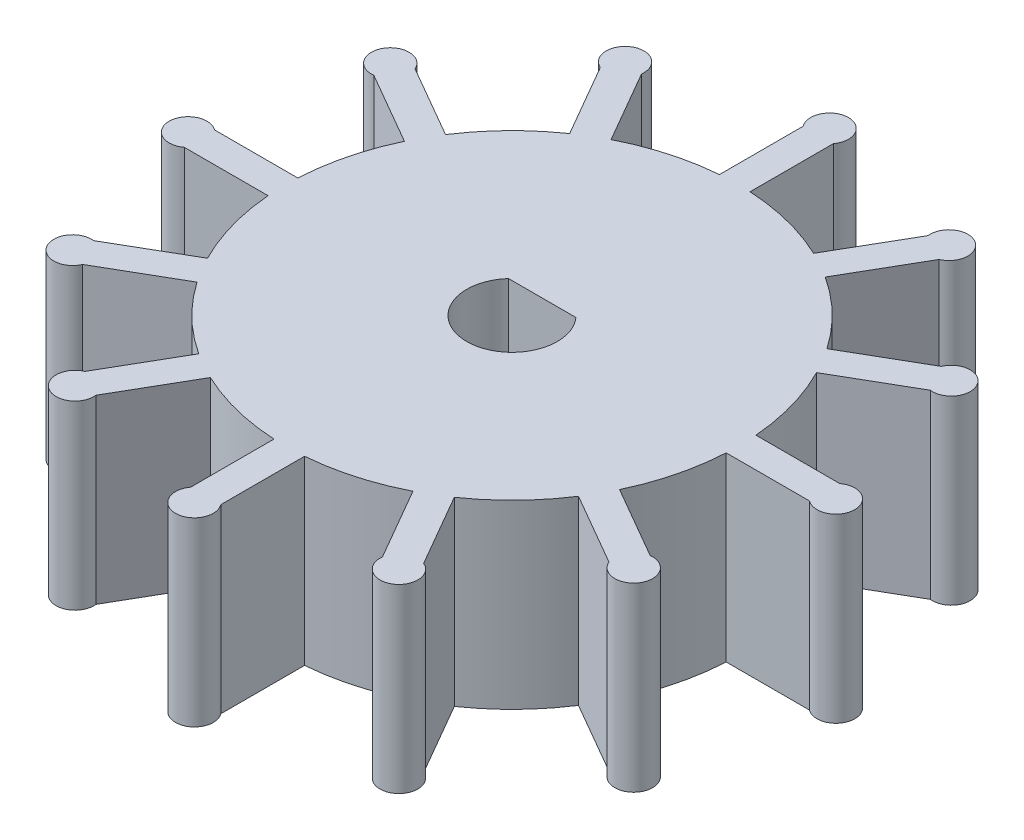
from build123d import *

# Parameters (mm, degrees)
BOSS_EXTRUDE1_DEPTH = 12
CUT_EXTRUDE1_DEPTH  = 13


with BuildPart() as part:
    # Sketch1 → Boss-Extrude1 (new body)
    with BuildSketch(Plane(origin=(0, 0, 0), x_dir=(1, 0, 0), z_dir=(0, 1, 0))):
        with BuildLine():
            Line((-1.209935044, 20.498962969), (-1.209935044, 14.951122272))
            ThreePointArc((-1.209935044, 14.951122272), (-4.085137635, 14.433005595), (-6.805373075, 13.367381842))
            Line((-6.805373075, 13.367381842), (-9.565265163, 18.147655161))
            ThreePointArc((-9.565265163, 18.147655161), (-11.431290566, 19.379705968), (-11.29731597, 17.147655161))
            Line((-11.29731597, 17.147655161), (-8.523395621, 12.34308418))
            ThreePointArc((-8.523395621, 12.34308418), (-10.754335768, 10.45678068), (-12.577316886, 8.17380572))
            Line((-12.577316886, 8.17380572), (-17.357590205, 10.933697807))
            ThreePointArc((-17.357590205, 10.933697807), (-19.589641013, 11.067672403), (-18.357590205, 9.201646999))
            Line((-18.357590205, 9.201646999), (-13.553019225, 6.427726651))
            ThreePointArc((-13.553019225, 6.427726651), (-14.541918316, 3.678669827), (-14.979178795, 0.790064956))
            Line((-14.979178795, 0.790064956), (-20.498962969, 0.790064956))
            ThreePointArc((-20.498962969, 0.790064956), (-22.498962969, -0.209935044), (-20.498962969, -1.209935044))
            Line((-20.498962969, -1.209935044), (-14.951122272, -1.209935044))
            ThreePointArc((-14.951122272, -1.209935044), (-14.433005595, -4.085137635), (-13.367381842, -6.805373075))
            Line((-13.367381842, -6.805373075), (-18.147655161, -9.565265163))
            ThreePointArc((-18.147655161, -9.565265163), (-19.379705968, -11.431290566), (-17.147655161, -11.29731597))
            Line((-17.147655161, -11.29731597), (-12.34308418, -8.523395621))
            ThreePointArc((-12.34308418, -8.523395621), (-10.45678068, -10.754335768), (-8.17380572, -12.577316886))
            Line((-8.17380572, -12.577316886), (-10.933697807, -17.357590205))
            ThreePointArc((-10.933697807, -17.357590205), (-11.067672403, -19.589641013), (-9.201646999, -18.357590205))
            Line((-9.201646999, -18.357590205), (-6.427726651, -13.553019225))
            ThreePointArc((-6.427726651, -13.553019225), (-3.678669827, -14.541918316), (-0.790064956, -14.979178795))
            Line((-0.790064956, -14.979178795), (-0.790064956, -20.498962969))
            ThreePointArc((-0.790064956, -20.498962969), (0.209935044, -22.498962969), (1.209935044, -20.498962969))
            Line((1.209935044, -20.498962969), (1.209935044, -14.951122272))
            ThreePointArc((1.209935044, -14.951122272), (4.085137635, -14.433005595), (6.805373075, -13.367381842))
            Line((6.805373075, -13.367381842), (9.565265163, -18.147655161))
            ThreePointArc((9.565265163, -18.147655161), (11.431290566, -19.379705968), (11.29731597, -17.147655161))
            Line((11.29731597, -17.147655161), (8.523395621, -12.34308418))
            ThreePointArc((8.523395621, -12.34308418), (10.754335768, -10.45678068), (12.577316886, -8.17380572))
            Line((12.577316886, -8.17380572), (17.357590205, -10.933697807))
            ThreePointArc((17.357590205, -10.933697807), (19.589641013, -11.067672403), (18.357590205, -9.201646999))
            Line((18.357590205, -9.201646999), (13.553019225, -6.427726651))
            ThreePointArc((13.553019225, -6.427726651), (14.541918316, -3.678669827), (14.979178795, -0.790064956))
            Line((14.979178795, -0.790064956), (20.498962969, -0.790064956))
            ThreePointArc((20.498962969, -0.790064956), (22.498962969, 0.209935044), (20.498962969, 1.209935044))
            Line((20.498962969, 1.209935044), (14.951122272, 1.209935044))
            ThreePointArc((14.951122272, 1.209935044), (14.433005595, 4.085137635), (13.367381842, 6.805373075))
            Line((13.367381842, 6.805373075), (18.147655161, 9.565265163))
            ThreePointArc((18.147655161, 9.565265163), (19.379705968, 11.431290566), (17.147655161, 11.29731597))
            Line((17.147655161, 11.29731597), (12.34308418, 8.523395621))
            ThreePointArc((12.34308418, 8.523395621), (10.45678068, 10.754335768), (8.17380572, 12.577316886))
            Line((8.17380572, 12.577316886), (10.933697807, 17.357590205))
            ThreePointArc((10.933697807, 17.357590205), (11.067672403, 19.589641013), (9.201646999, 18.357590205))
            Line((9.201646999, 18.357590205), (6.427726651, 13.553019225))
            ThreePointArc((6.427726651, 13.553019225), (3.678669827, 14.541918316), (0.790064956, 14.979178795))
            Line((0.790064956, 14.979178795), (0.790064956, 20.498962969))
            ThreePointArc((0.790064956, 20.498962969), (-0.209935044, 22.498962969), (-1.209935044, 20.498962969))
        make_face()
    extrude(amount=BOSS_EXTRUDE1_DEPTH)

    # Sketch2 → Cut-Extrude1 (cut, through all)
    with BuildSketch(Plane(origin=(0, 12, 0), x_dir=(1, 0, 0), z_dir=(0, 1, 0))):
        with BuildLine():
            Line((-2.236067977, 2), (2.236067977, 2))
            ThreePointArc((2.236067977, 2), (0, -3), (-2.236067977, 2))
        make_face()
    extrude(amount=-CUT_EXTRUDE1_DEPTH, mode=Mode.SUBTRACT)


solid = part.part
